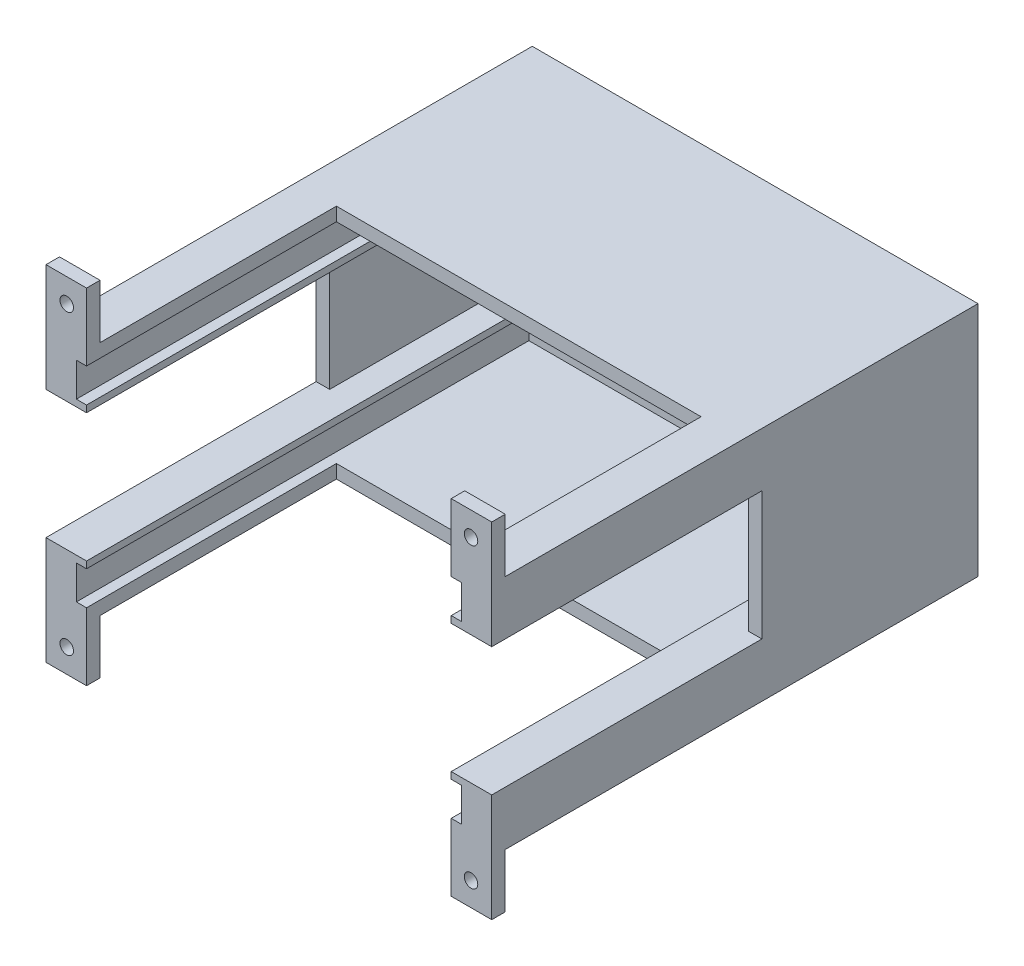
from build123d import *

# Parameters (mm, degrees)
ESQUISSE1_W               = 66
ESQUISSE1_H               = 35
BOSS_EXTRU_1_DEPTH        = 70
ESQUISSE2_W               = 54
ESQUISSE2_H               = 35
ENL_V_MAT_EXTRU_2_DEPTH   = 65
ESQUISSE4_W               = 54
ESQUISSE4_H               = 2
BOSS_EXTRU_2_DEPTH        = 30
ESQUISSE5_W               = 6
ESQUISSE5_H               = 51
BOSS_EXTRU_3_DEPTH        = 2
ESQUISSE6_R               = 1
ENL_V_MAT_EXTRU_3_DEPTH   = 10
SYM_TRIE3_COPY_1_SKETCH_R = 1
SYM_TRIE3_COPY_1_DEPTH    = 10
ESQUISSE12_R              = 2.5
ENL_V_MAT_EXTRU_5_DEPTH   = 0.5
ENL_V_MAT_EXTRU_6_DEPTH   = 2
ESQUISSE15_W              = 12
ESQUISSE15_H              = 12
ESQUISSE15_W_2            = 10
ESQUISSE15_H_2            = 15
ENL_V_MAT_EXTRU_8_DEPTH   = 3
ESQUISSE17_W              = 40
ESQUISSE17_H              = 19
ENL_V_MAT_EXTRU_10_DEPTH  = 67
ESQUISSE18_W              = 4
ESQUISSE18_H              = 19
ENL_V_MAT_EXTRU_11_DEPTH  = 30
ESQUISSE20_W              = 67
ESQUISSE20_H              = 5
ENL_V_MAT_EXTRU_13_DEPTH  = 1.5
SYM_TRIE5_COPY_1_SKETCH_W = 67
SYM_TRIE5_COPY_1_SKETCH_H = 5
SYM_TRIE5_COPY_1_DEPTH    = 1.5
ESQUISSE22_W              = 1
ESQUISSE22_H              = 7
ENL_V_MAT_EXTRU_14_DEPTH  = 73


with BuildPart() as part:
    # Esquisse1 → Boss.-Extru.1 (new body)
    with BuildSketch(Plane.XY):
        Rectangle(ESQUISSE1_W, ESQUISSE1_H)
    extrude(amount=BOSS_EXTRU_1_DEPTH)

    # Esquisse2 → Enlèv. mat.-Extru.2 (cut)
    with BuildSketch(Plane.XY.offset(70)):
        Rectangle(ESQUISSE2_W, ESQUISSE2_H)
    extrude(amount=-ENL_V_MAT_EXTRU_2_DEPTH, mode=Mode.SUBTRACT)

    # Esquisse4 → Boss.-Extru.2 (add)
    with BuildSketch(Plane.XY.offset(5)):
        with Locations((0, 16.5)):
            Rectangle(ESQUISSE4_W, ESQUISSE4_H)
    boss_extru_2 = extrude(amount=BOSS_EXTRU_2_DEPTH)

    # Symétrie1: Boss.-Extru.2 across plane
    add(boss_extru_2.mirror(Plane.ZX))

    # Esquisse5 → Boss.-Extru.3 (add)
    with BuildSketch(Plane.XY.offset(70)):
        with Locations((-30, 0)):
            Rectangle(ESQUISSE5_W, ESQUISSE5_H)
    boss_extru_3 = extrude(amount=BOSS_EXTRU_3_DEPTH)

    # Esquisse6 → Enlèv. mat.-Extru.3 (cut)
    with BuildSketch(Plane(origin=(0, 0, 70), x_dir=(-1, 0, 0), z_dir=(0, 0, -1))):
        with Locations((29.930394318, 22)):
            Circle(ESQUISSE6_R)
    enl_v_mat_extru_3 = extrude(amount=-ENL_V_MAT_EXTRU_3_DEPTH, mode=Mode.SUBTRACT)

    # Symétrie2: Enlèv. mat.-Extru.3 across plane
    add(enl_v_mat_extru_3.mirror(Plane.ZX), mode=Mode.SUBTRACT)

    # Symétrie3: Boss.-Extru.3, Enlèv. mat.-Extru.3 across plane
    add(boss_extru_3.mirror(Plane(origin=(0, 0, 0), x_dir=(0, 0, 1), z_dir=(1, 0, 0))))
    add(enl_v_mat_extru_3.mirror(Plane(origin=(0, 0, 0), x_dir=(0, 0, 1), z_dir=(1, 0, 0))), mode=Mode.SUBTRACT)

    # Symétrie3 copy 1 sketch → Symétrie3 copy 1 (cut)
    with BuildSketch(Plane(origin=(0, 0, 70), x_dir=(1, 0, 0), z_dir=(0, 0, -1))):
        with Locations((29.930394318, 22)):
            Circle(SYM_TRIE3_COPY_1_SKETCH_R)
    extrude(amount=-SYM_TRIE3_COPY_1_DEPTH, mode=Mode.SUBTRACT)

    # Esquisse12 → Enlèv. mat.-Extru.5 (cut)
    with BuildSketch(Plane(origin=(0, 0, 0), x_dir=(-1, 0, 0), z_dir=(0, 0, -1))):
        with Locations((0, -12.5)):
            Circle(ESQUISSE12_R)
    extrude(amount=-ENL_V_MAT_EXTRU_5_DEPTH, mode=Mode.SUBTRACT)

    # Esquisse14 → Enlèv. mat.-Extru.6 (cut)
    with BuildSketch(Plane(origin=(0, 0, 0.5), x_dir=(-1, 0, 0), z_dir=(0, 0, -1))):
        with BuildLine():
            Line((0.4, -11.25), (0.4, -13.75))
            ThreePointArc((0.4, -13.75), (0, -14.15), (-0.4, -13.75))
            Line((-0.4, -13.75), (-0.4, -11.25))
            ThreePointArc((-0.4, -11.25), (0, -10.85), (0.4, -11.25))
        make_face()
    extrude(amount=-ENL_V_MAT_EXTRU_6_DEPTH, mode=Mode.SUBTRACT)

    # Esquisse15 → Enlèv. mat.-Extru.8 (cut)
    with BuildSketch(Plane(origin=(0, 0, 0), x_dir=(-1, 0, 0), z_dir=(0, 0, -1))):
        with Locations((1, 3.5)):
            Rectangle(ESQUISSE15_W, ESQUISSE15_H)
        with Locations((-19, 3.5)):
            Rectangle(ESQUISSE15_W, ESQUISSE15_H)
        with Locations((20, 4)):
            Rectangle(ESQUISSE15_W_2, ESQUISSE15_H_2)
    extrude(amount=-ENL_V_MAT_EXTRU_8_DEPTH, mode=Mode.SUBTRACT)

    # Esquisse17 → Enlèv. mat.-Extru.10 (cut, through all)
    with BuildSketch(Plane.ZY.offset(33)):
        with Locations((52, 0)):
            Rectangle(ESQUISSE17_W, ESQUISSE17_H)
    extrude(amount=-ENL_V_MAT_EXTRU_10_DEPTH, mode=Mode.SUBTRACT)

    # Esquisse18 → Enlèv. mat.-Extru.11 (cut)
    with BuildSketch(Plane.XY.offset(32)):
        with Locations((29, 0)):
            Rectangle(ESQUISSE18_W, ESQUISSE18_H)
    enl_v_mat_extru_11 = extrude(amount=-ENL_V_MAT_EXTRU_11_DEPTH, mode=Mode.SUBTRACT)

    # Esquisse20 → Enlèv. mat.-Extru.13 (cut)
    with BuildSketch(Plane.ZY.offset(-27)):
        with Locations((38.5, -13)):
            Rectangle(ESQUISSE20_W, ESQUISSE20_H)
    enl_v_mat_extru_13 = extrude(amount=-ENL_V_MAT_EXTRU_13_DEPTH, mode=Mode.SUBTRACT)

    # Symétrie4: Enlèv. mat.-Extru.13 across plane
    add(enl_v_mat_extru_13.mirror(Plane.ZX), mode=Mode.SUBTRACT)

    # Symétrie5: Enlèv. mat.-Extru.13, Enlèv. mat.-Extru.11 across plane
    add(enl_v_mat_extru_13.mirror(Plane(origin=(0, 0, 0), x_dir=(0, 0, 1), z_dir=(1, 0, 0))), mode=Mode.SUBTRACT)
    add(enl_v_mat_extru_11.mirror(Plane(origin=(0, 0, 0), x_dir=(0, 0, 1), z_dir=(1, 0, 0))), mode=Mode.SUBTRACT)

    # Symétrie5 copy 1 sketch → Symétrie5 copy 1 (cut)
    with BuildSketch(Plane(origin=(-27, 0, 0), x_dir=(0, 0, 1), z_dir=(1, 0, 0))):
        with Locations((38.5, -13)):
            Rectangle(SYM_TRIE5_COPY_1_SKETCH_W, SYM_TRIE5_COPY_1_SKETCH_H)
    extrude(amount=-SYM_TRIE5_COPY_1_DEPTH, mode=Mode.SUBTRACT)

    # Esquisse22 → Enlèv. mat.-Extru.14 (cut, through all)
    with BuildSketch(Plane(origin=(0, 0, 0), x_dir=(-1, 0, 0), z_dir=(0, 0, -1))):
        with Locations((-12.5, 3.5)):
            Rectangle(ESQUISSE22_W, ESQUISSE22_H)
        with Locations((-25.5, 3.5)):
            Rectangle(ESQUISSE22_W, ESQUISSE22_H)
        with Locations((-5.5, 3.5)):
            Rectangle(ESQUISSE22_W, ESQUISSE22_H)
        with Locations((7.5, 3.5)):
            Rectangle(ESQUISSE22_W, ESQUISSE22_H)
    extrude(amount=-ENL_V_MAT_EXTRU_14_DEPTH, mode=Mode.SUBTRACT)


solid = part.part
